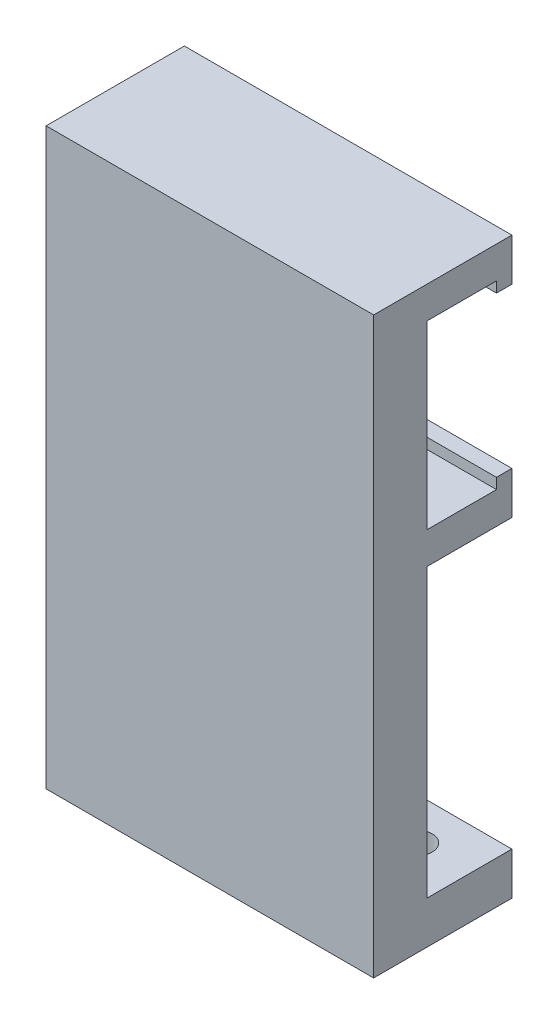
from build123d import *

# Parameters (mm, degrees)
SKETCH_1_W          = 30.8
SKETCH_1_H          = 54
EXTRUDE_1_DEPTH     = 5
SKETCH_2_W          = 30.8
SKETCH_2_H          = 4
EXTRUDE_2_DEPTH     = 8
SKETCH_3_R          = 1.5
CUT_EXTRUDE_1_DEPTH = 5
SKETCH_4_W          = 30.8
SKETCH_4_H          = 3
EXTRUDE_3_DEPTH     = 8
SKETCH_5_W          = 30.8
SKETCH_5_H          = 1.45
EXTRUDE_4_DEPTH     = 1
SKETCH_6_W          = 30.8
SKETCH_6_H          = 1.45
EXTRUDE_5_DEPTH     = 1
SKETCH_7_W          = 5
SKETCH_7_H          = 22
EXTRUDE_6_DEPTH     = 8


with BuildPart() as part:
    # 草图1 → 凸台-拉伸1 (new body)
    with BuildSketch(Plane.XY):
        Rectangle(SKETCH_1_W, SKETCH_1_H)
    extrude(amount=EXTRUDE_1_DEPTH)

    # 草图2 → 凸台-拉伸2 (add)
    with BuildSketch(Plane(origin=(0, 0, 0), x_dir=(-1, 0, 0), z_dir=(0, 0, -1))):
        with Locations((0, -25)):
            Rectangle(SKETCH_2_W, SKETCH_2_H)
    extrude(amount=EXTRUDE_2_DEPTH)

    # 草图3 → 切除-拉伸1 (cut, through all)
    with BuildSketch(Plane(origin=(0, -23, 0), x_dir=(1, 0, 0), z_dir=(0, 1, 0))):
        with Locations((10.4, 4)):
            Circle(SKETCH_3_R)
        with Locations((-10.4, 4)):
            Circle(SKETCH_3_R)
    extrude(amount=-CUT_EXTRUDE_1_DEPTH, mode=Mode.SUBTRACT)

    # 草图4 → 凸台-拉伸3 (add)
    with BuildSketch(Plane(origin=(0, 0, 0), x_dir=(-1, 0, 0), z_dir=(0, 0, -1))):
        with Locations((0, 25.5)):
            Rectangle(SKETCH_4_W, SKETCH_4_H)
        with Locations((0, 5.5)):
            Rectangle(SKETCH_4_W, SKETCH_4_H)
    extrude(amount=EXTRUDE_3_DEPTH)

    # 草图5 → 凸台-拉伸4 (add)
    with BuildSketch(Plane(origin=(0, 7, 0), x_dir=(1, 0, 0), z_dir=(0, 1, 0))):
        with Locations((0, 7.275)):
            Rectangle(SKETCH_5_W, SKETCH_5_H)
    extrude(amount=EXTRUDE_4_DEPTH)

    # 草图6 → 凸台-拉伸5 (add)
    with BuildSketch(Plane.XZ.offset(-24)):
        with Locations((0, -7.275)):
            Rectangle(SKETCH_6_W, SKETCH_6_H)
    extrude(amount=EXTRUDE_5_DEPTH)

    # 草图7 → 凸台-拉伸6 (add)
    with BuildSketch(Plane(origin=(0, 0, 0), x_dir=(-1, 0, 0), z_dir=(0, 0, -1))):
        with Locations((0, -7)):
            Rectangle(SKETCH_7_W, SKETCH_7_H)
    extrude(amount=EXTRUDE_6_DEPTH)


solid = part.part
